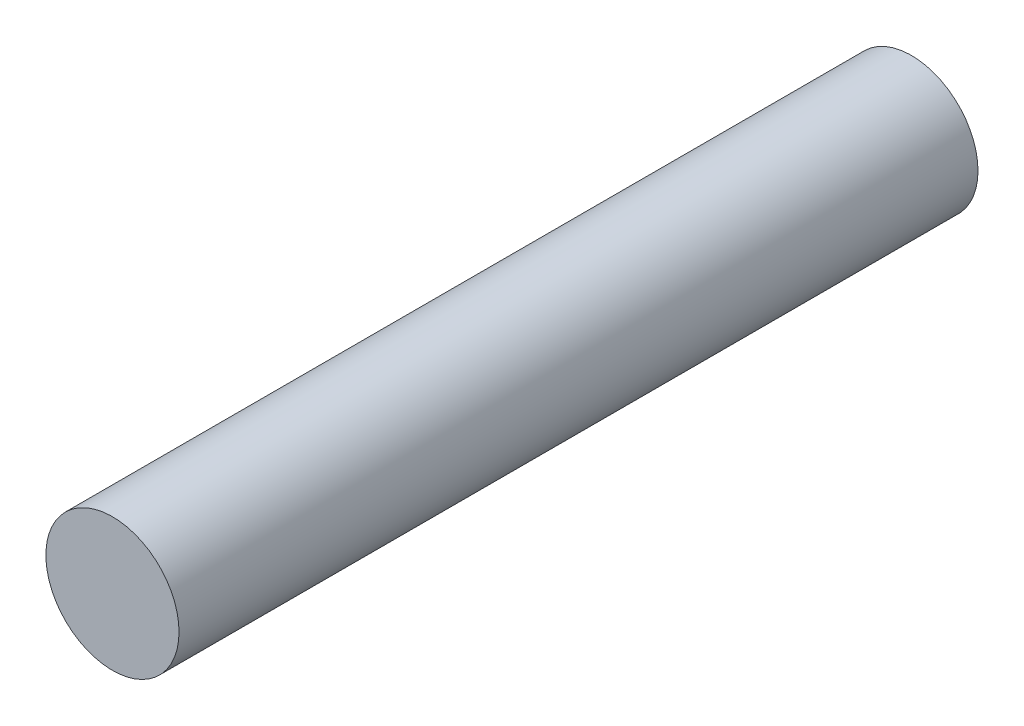
from build123d import *

# Parameters (mm, degrees)
SKETCH1_R           = 2.5
BOSS_EXTRUDE1_DEPTH = 30


with BuildPart() as part:
    # Sketch1 → Boss-Extrude1 (new body)
    with BuildSketch(Plane.XY):
        Circle(SKETCH1_R)
    extrude(amount=BOSS_EXTRUDE1_DEPTH)


solid = part.part
